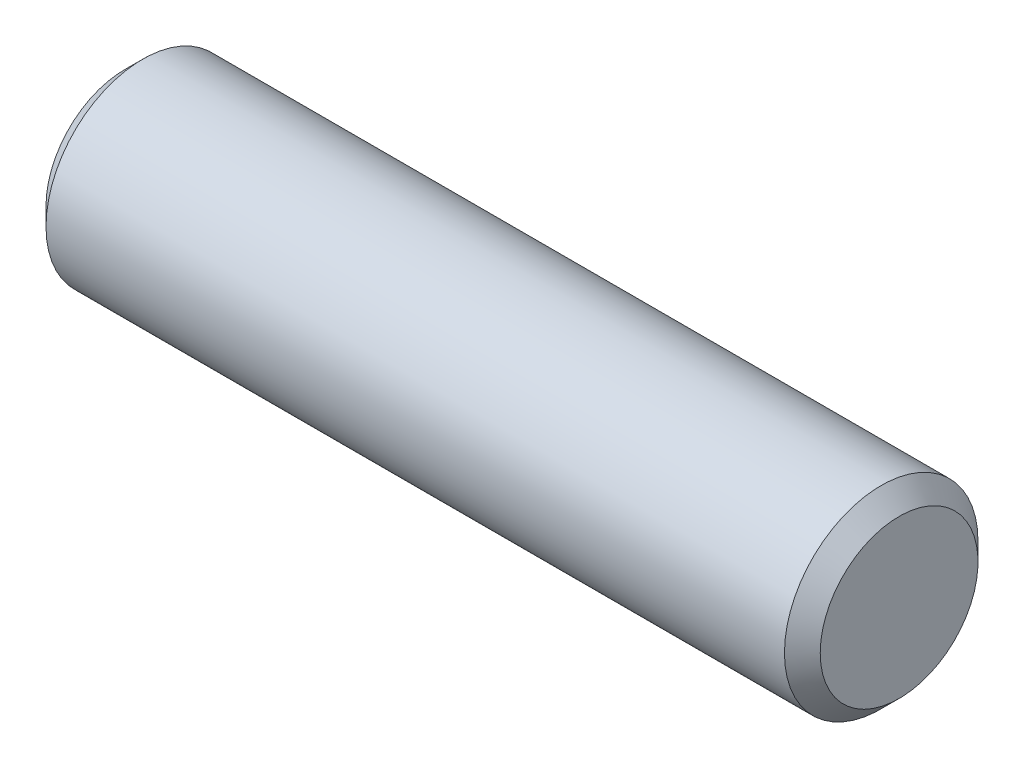
from build123d import *


with BuildPart() as part:
    # BodySke → BaseBody (revolve)
    with BuildSketch(Plane.XY):
        Polygon((-12, 2.4455), (-12, 0), (12, 0), (12, 2.4455), (11.4455, 3), (-11.4455, 3), align=None)
    revolve(axis=Axis((0, 0, 0), (1, 0, 0)))


solid = part.part
